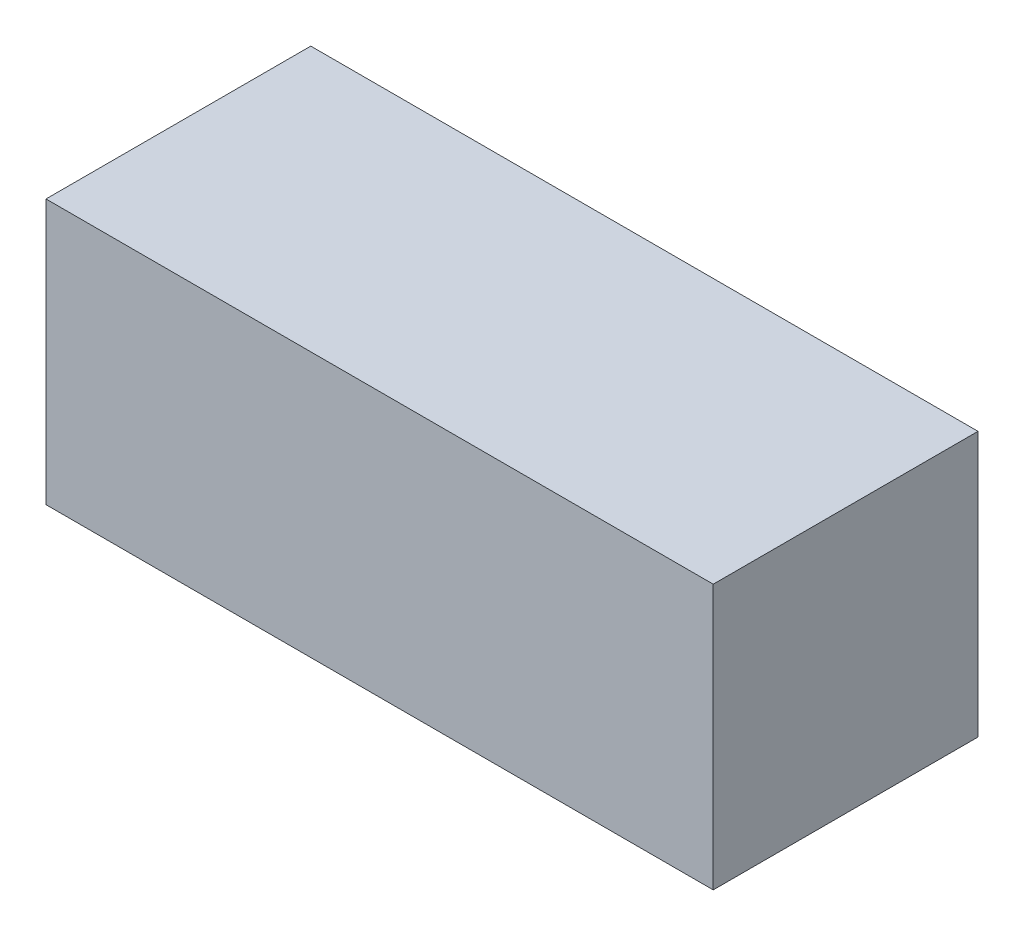
from build123d import *

# Parameters (mm, degrees)
SKETCH1_W           = 63
SKETCH1_H           = 25
BOSS_EXTRUDE1_DEPTH = 25


with BuildPart() as part:
    # Sketch1 → Boss-Extrude1 (new body)
    with BuildSketch(Plane(origin=(0, 0, 0), x_dir=(1, 0, 0), z_dir=(0, 1, 0))):
        Rectangle(SKETCH1_W, SKETCH1_H)
    extrude(amount=BOSS_EXTRUDE1_DEPTH)


solid = part.part
